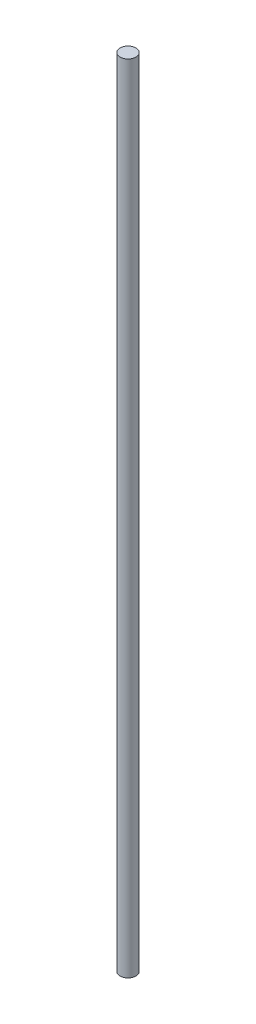
from build123d import *

# Parameters (mm, degrees)
CROQUIS2_R = 4


with BuildPart() as part:
    # Barrer1: sweep along a path in Croquis1
    with BuildLine(Plane.XY) as barrer1_path:
        Line((0, 0), (0, 400))
    # Croquis2 → Barrer1 (sweep)
    with BuildSketch(Plane(origin=(0, 0, 0), x_dir=(1, 0, 0), z_dir=(0, 1, 0))):
        Circle(CROQUIS2_R)
    sweep(path=barrer1_path.line)


solid = part.part
